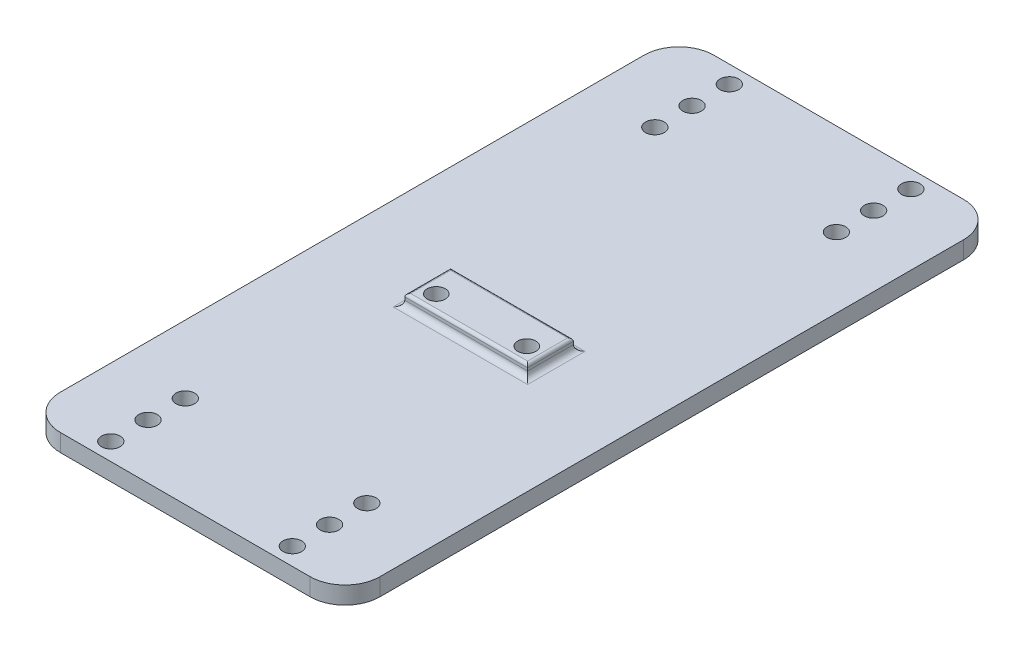
from build123d import *

# Parameters (mm, degrees)
SKETCH1_W           = 54.92426628
SKETCH1_H           = 112.31
SKETCH1_R           = 1.6
BOSS_EXTRUDE1_DEPTH = 3
FILLET1_R           = 6
SKETCH2_W           = 21.1074
SKETCH2_H           = 7.874
SKETCH2_R           = 1.55575
BOSS_EXTRUDE2_DEPTH = 2
SKETCH2_4_R         = 1.55575
CUT_EXTRUDE1_DEPTH  = 132.116486444
FILLET2_R           = 1
FILLET3_R           = 0.5


with BuildPart() as part:
    # Sketch1 → Boss-Extrude1 (new body)
    with BuildSketch(Plane(origin=(0, 0, 0), x_dir=(1, 0, 0), z_dir=(0, 1, 0))):
        with Locations((-64.799805622, 36.959272125)):
            Rectangle(SKETCH1_W, SKETCH1_H)
        with Locations((-80.599805622, -16.191669117)):
            Circle(SKETCH1_R, mode=Mode.SUBTRACT)
        with Locations((-80.599805622, -9.791669117)):
            Circle(SKETCH1_R, mode=Mode.SUBTRACT)
        with Locations((-80.599805622, -3.391669117)):
            Circle(SKETCH1_R, mode=Mode.SUBTRACT)
        with Locations((-49.399805622, -3.391669117)):
            Circle(SKETCH1_R, mode=Mode.SUBTRACT)
        with Locations((-49.399805622, -9.791669117)):
            Circle(SKETCH1_R, mode=Mode.SUBTRACT)
        with Locations((-49.399805622, -16.191669117)):
            Circle(SKETCH1_R, mode=Mode.SUBTRACT)
        with Locations((-49.399805622, 90.110213368)):
            Circle(SKETCH1_R, mode=Mode.SUBTRACT)
        with Locations((-49.399805622, 83.710213368)):
            Circle(SKETCH1_R, mode=Mode.SUBTRACT)
        with Locations((-49.399805622, 77.310213368)):
            Circle(SKETCH1_R, mode=Mode.SUBTRACT)
        with Locations((-80.599805622, 77.310213368)):
            Circle(SKETCH1_R, mode=Mode.SUBTRACT)
        with Locations((-80.599805622, 83.710213368)):
            Circle(SKETCH1_R, mode=Mode.SUBTRACT)
        with Locations((-80.599805622, 90.110213368)):
            Circle(SKETCH1_R, mode=Mode.SUBTRACT)
    extrude(amount=BOSS_EXTRUDE1_DEPTH)

    # Fillet1
    fillet1_edges = [part.edges().sort_by_distance(p)[0] for p in [
        (-92.261938762, 1.5, -93.114272125),
        (-37.337672482, 1.5, -93.114272125),
        (-92.261938762, 1.5, 19.195727875),
        (-37.337672482, 1.5, 19.195727875),
    ]]
    fillet(fillet1_edges, radius=FILLET1_R)

    # Sketch2 → Boss-Extrude2 (add)
    with BuildSketch(Plane(origin=(0, 3, 0), x_dir=(1, 0, 0), z_dir=(0, 1, 0))):
        with Locations((-64.799805622, 33.022272125)):
            Rectangle(SKETCH2_W, SKETCH2_H)
        with Locations((-72.578555622, 31.720522125)):
            Circle(SKETCH2_R, mode=Mode.SUBTRACT)
        with Locations((-57.021525285, 31.719768414)):
            Circle(SKETCH2_R, mode=Mode.SUBTRACT)
    extrude(amount=BOSS_EXTRUDE2_DEPTH)

    # Sketch2_4 → Cut-Extrude1 (cut, through all)
    with BuildSketch(Plane(origin=(0, 3, 0), x_dir=(1, 0, 0), z_dir=(0, 1, 0))):
        with Locations((-72.578555622, 31.720522125)):
            Circle(SKETCH2_4_R)
        with Locations((-57.021525285, 31.719768414)):
            Circle(SKETCH2_4_R)
    extrude(amount=-CUT_EXTRUDE1_DEPTH, mode=Mode.SUBTRACT)

    # Fillet2
    fillet2_edges = [part.edges().sort_by_distance(p)[0] for p in [
        (-75.353505622, 3, -33.022272125),
        (-64.799805622, 3, -36.959272125),
        (-64.799805622, 3, -29.085272125),
        (-54.246105622, 3, -33.022272125),
    ]]
    fillet(fillet2_edges, radius=FILLET2_R)

    # Fillet3
    fillet3_edges = [part.edges().sort_by_distance(p)[0] for p in [
        (-54.246105622, 5, -33.022272125),
        (-64.799805622, 5, -36.959272125),
        (-75.353505622, 5, -33.022272125),
        (-64.799805622, 5, -29.085272125),
    ]]
    fillet(fillet3_edges, radius=FILLET3_R)


solid = part.part
